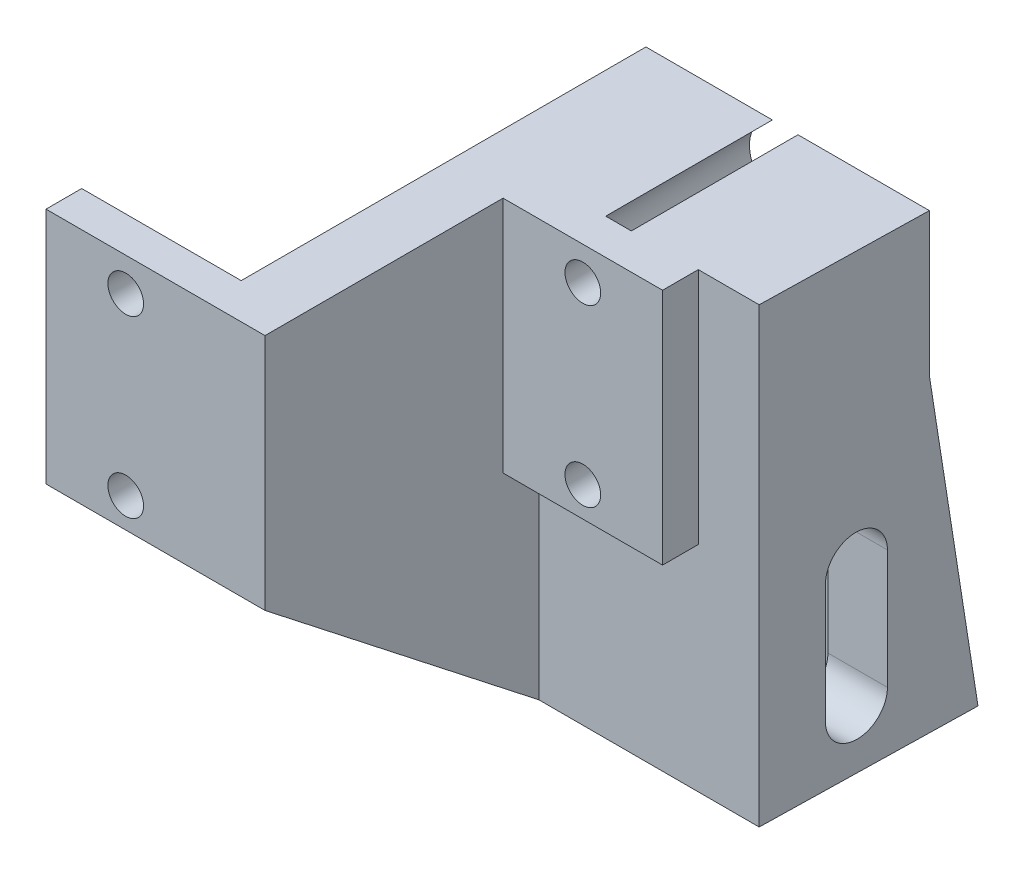
from build123d import *

# Parameters (mm, degrees)
BOSS_EXTRUDE1_DEPTH              = 20
CUT_EXTRUDE1_START               = -4
SKETCH2_R                        = 1.5
CUT_EXTRUDE1_DEPTH               = 25
BOSS_EXTRUDE2_DEPTH              = 23.9
SKETCH4_R                        = 3
CUT_EXTRUDE2_DEPTH               = 19
BOSS_EXTRUDE3_DEPTH              = 5
CUT_EXTRUDE3_DEPTH               = 39
CUT_EXTRUDE4_REACH               = 30.9
CUT_EXTRUDE4_OFFSET_FROM_SURFACE = 5


with BuildPart() as part:
    # Sketch1 → Boss-Extrude1 (new body)
    with BuildSketch(Plane(origin=(0, 0, 0), x_dir=(1, 0, 0), z_dir=(0, 1, 0))):
        Polygon((0, 0), (18.4, 0), (18.4, 20), (31.8, 20), (31.8, 23), (13.4, 23), (13.4, 3), (0, 3), align=None)
    extrude(amount=BOSS_EXTRUDE1_DEPTH)

    # Sketch2 → Cut-Extrude1 (cut)
    with BuildSketch(Plane.XY.offset(-20).offset(CUT_EXTRUDE1_START)):
        with Locations((25.1, 2.5)):
            Circle(SKETCH2_R)
        with Locations((25.1, 17.2)):
            Circle(SKETCH2_R)
    cut_extrude1 = extrude(amount=CUT_EXTRUDE1_DEPTH, mode=Mode.SUBTRACT)

    # Mirror1: Cut-Extrude1 across plane
    add(cut_extrude1.mirror(Plane.ZY.offset(-15.9)), mode=Mode.SUBTRACT)

    # Sketch3 → Boss-Extrude2 (add)
    with BuildSketch(Plane.ZY.offset(-13.4)):
        Polygon((-23, 0), (-23, -18), (-41, -18), (-37, 8), (-37, 20), (-23, 20), align=None)
        with BuildLine():
            Line((-33.55, -13), (-33.55, -3))
            ThreePointArc((-33.55, -3), (-31, -0.45), (-28.45, -3))
            Line((-28.45, -3), (-28.45, -13))
            ThreePointArc((-28.45, -13), (-31, -15.55), (-33.55, -13))
        make_face(mode=Mode.SUBTRACT)
    extrude(amount=-BOSS_EXTRUDE2_DEPTH)

    # Sketch4 → Cut-Extrude2 (cut, through all)
    with BuildSketch(Plane.XY.offset(-23)):
        with Locations((25.1, 2.5)):
            Circle(SKETCH4_R)
        with Locations((25.1, 17.2)):
            Circle(SKETCH4_R)
    extrude(amount=-CUT_EXTRUDE2_DEPTH, mode=Mode.SUBTRACT)

    # Sketch5 → Boss-Extrude3 (add)
    with BuildSketch(Plane.ZY.offset(-13.4)):
        Polygon((0, 0), (-23, -18), (-23, 0), align=None)
    extrude(amount=-BOSS_EXTRUDE3_DEPTH)

    # Sketch8 → Cut-Extrude3 (cut, through all)
    with BuildSketch(Plane.XZ.offset(18)):
        Polygon((37.3, -41), (36.916667761, -23), (37.3, -23), align=None)
    extrude(amount=-CUT_EXTRUDE3_DEPTH, mode=Mode.SUBTRACT)

    # Cut-Extrude4: up to this face of the body (flat: up to its plane, moved by the offset)
    cut_extrude4_end = Plane(part.part.faces().sort_by_distance((37.080777775, 1.205864864, -30.706057437))[0]).offset(-CUT_EXTRUDE4_OFFSET_FROM_SURFACE)
    # Sketch9 → Cut-Extrude4 (cut, up to the picked face)
    with BuildSketch(Plane.ZY.offset(-13.4), mode=Mode.PRIVATE) as cut_extrude4_sk1:
        with BuildLine():
            Line((-37, -3), (-37, -18))
            Line((-37, -18), (-25, -18))
            Line((-25, -18), (-25, -3))
            ThreePointArc((-25, -3), (-31, 3), (-37, -3))
        make_face()
    cut_extrude4_tool1 = split(extrude(cut_extrude4_sk1.sketch, amount=-CUT_EXTRUDE4_REACH, mode=Mode.PRIVATE), bisect_by=cut_extrude4_end, keep=Keep.BOTH, mode=Mode.PRIVATE)
    add(cut_extrude4_tool1.solids().sort_by_distance((13.4, -8.098317, -31))[0], mode=Mode.SUBTRACT)


solid = part.part
